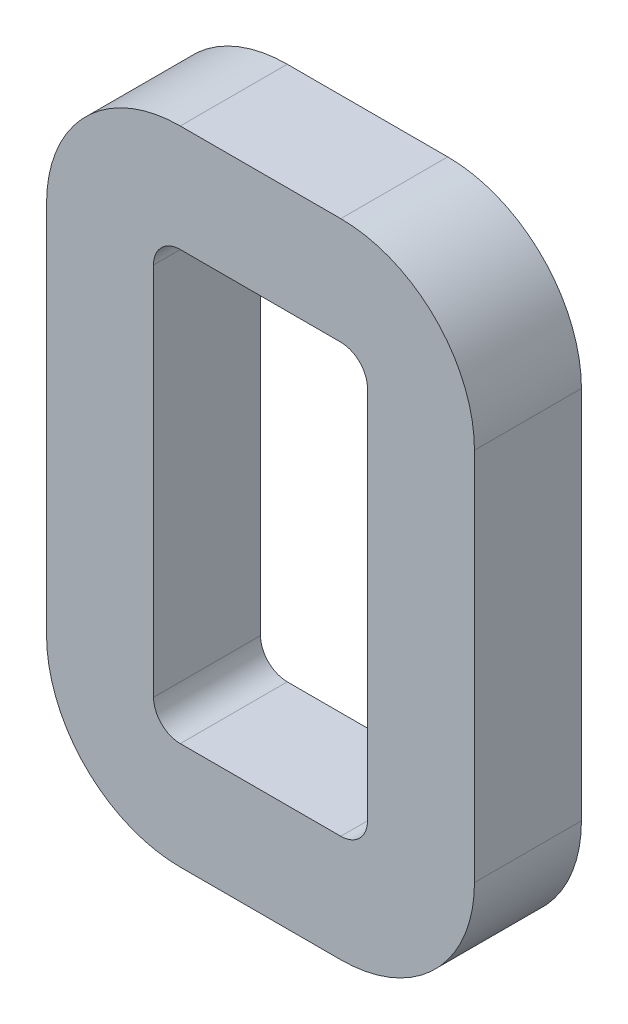
from build123d import *

# Parameters (mm, degrees)
BOSS_EXTRUDE1_DEPTH = 12.7


with BuildPart() as part:
    # Sketch2 → Boss-Extrude1 (new body)
    with BuildSketch(Plane.XY):
        with BuildLine():
            Line((-12.7, 3.175), (-12.7, 47.625))
            ThreePointArc((-12.7, 47.625), (-8.050320151, 58.850320151), (3.175, 63.5))
            Line((3.175, 63.5), (22.225, 63.5))
            ThreePointArc((22.225, 63.5), (33.450320151, 58.850320151), (38.1, 47.625))
            Line((38.1, 47.625), (38.1, 3.175))
            ThreePointArc((38.1, 3.175), (33.450320151, -8.050320151), (22.225, -12.7))
            Line((22.225, -12.7), (3.175, -12.7))
            ThreePointArc((3.175, -12.7), (-8.050320151, -8.050320151), (-12.7, 3.175))
        make_face()
        with BuildLine():
            Line((3.175, 0), (22.225, 0))
            ThreePointArc((22.225, 0), (24.47006403, 0.92993597), (25.4, 3.175))
            Line((25.4, 3.175), (25.4, 47.625))
            ThreePointArc((25.4, 47.625), (24.47006403, 49.87006403), (22.225, 50.8))
            Line((22.225, 50.8), (3.175, 50.8))
            ThreePointArc((3.175, 50.8), (0.92993597, 49.87006403), (0, 47.625))
            Line((0, 47.625), (0, 3.175))
            ThreePointArc((0, 3.175), (0.92993597, 0.92993597), (3.175, 0))
        make_face(mode=Mode.SUBTRACT)
    extrude(amount=BOSS_EXTRUDE1_DEPTH)


solid = part.part
